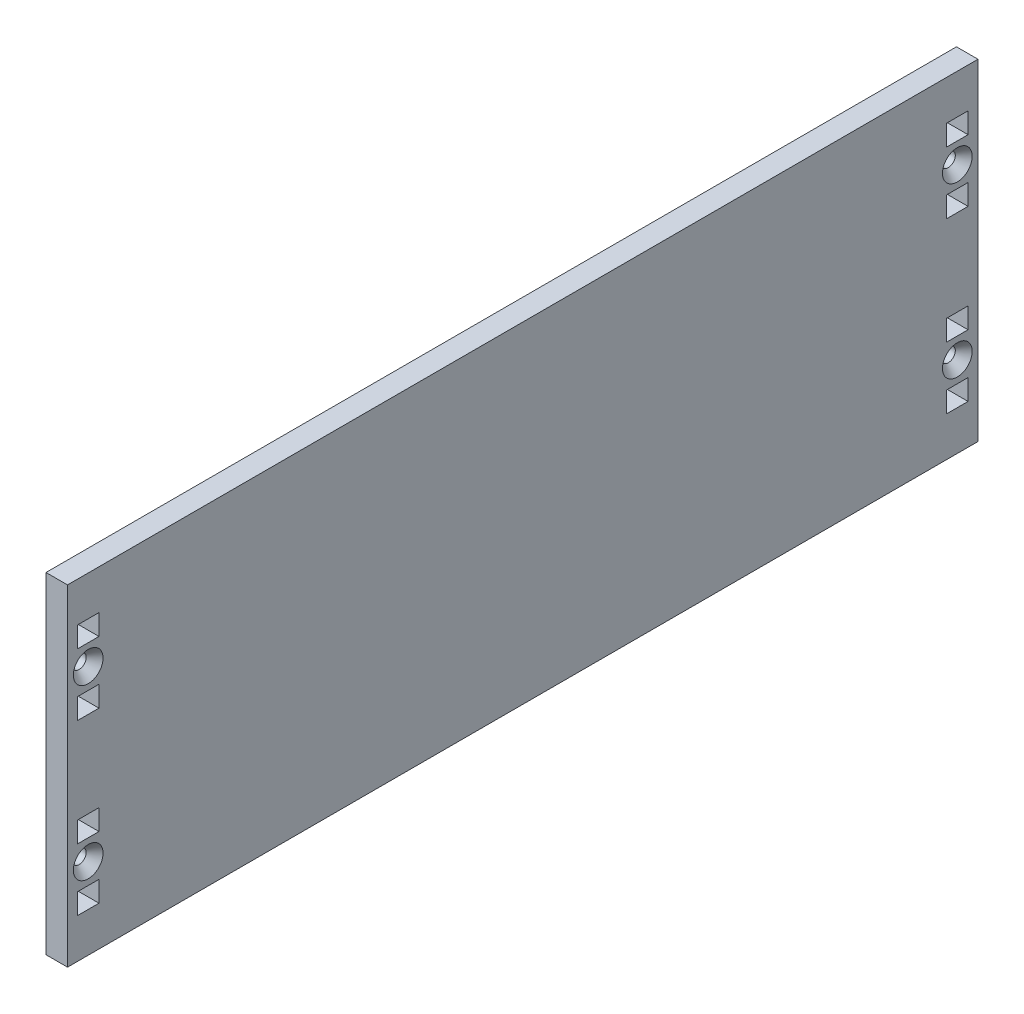
from build123d import *

# Parameters (mm, degrees)
SKETCH1_W                                         = 279.4
SKETCH1_H                                         = 101.6
SKETCH1_R                                         = 2.15265
SKETCH1_W_2                                       = 6.604
SKETCH1_H_2                                       = 6.35
BOSS_EXTRUDE1_DEPTH                               = 6.604
CSK_FOR_8_FLAT_HEAD_SOCKET_CAP_SCREW1_D           = 4.3053
CSK_FOR_8_FLAT_HEAD_SOCKET_CAP_SCREW1_CSINK_D     = 9.1186
CSK_FOR_8_FLAT_HEAD_SOCKET_CAP_SCREW1_CSINK_ANGLE = 82


with BuildPart() as part:
    # Sketch1 → Boss-Extrude1 (new body)
    with BuildSketch(Plane(origin=(0, 0, 0), x_dir=(0, 0, -1), z_dir=(1, 0, 0))):
        with Locations((0, -50.8)):
            Rectangle(SKETCH1_W, SKETCH1_H)
        with Locations((-133.35, -24.8793)):
            Circle(SKETCH1_R, mode=Mode.SUBTRACT)
        with Locations((-133.35, -76.7207)):
            Circle(SKETCH1_R, mode=Mode.SUBTRACT)
        with Locations((133.35, -24.8793)):
            Circle(SKETCH1_R, mode=Mode.SUBTRACT)
        with Locations((133.35, -76.720700102)):
            Circle(SKETCH1_R, mode=Mode.SUBTRACT)
        with Locations((-133.35, -34.4043)):
            Rectangle(SKETCH1_W_2, SKETCH1_H_2, mode=Mode.SUBTRACT)
        with Locations((-133.35, -15.3543)):
            Rectangle(SKETCH1_W_2, SKETCH1_H_2, mode=Mode.SUBTRACT)
        with Locations((-133.35, -86.2457)):
            Rectangle(SKETCH1_W_2, SKETCH1_H_2, mode=Mode.SUBTRACT)
        with Locations((-133.35, -67.1957)):
            Rectangle(SKETCH1_W_2, SKETCH1_H_2, mode=Mode.SUBTRACT)
        with Locations((133.35, -15.3543)):
            Rectangle(SKETCH1_W_2, SKETCH1_H_2, mode=Mode.SUBTRACT)
        with Locations((133.35, -34.4043)):
            Rectangle(SKETCH1_W_2, SKETCH1_H_2, mode=Mode.SUBTRACT)
        with Locations((133.35, -67.195700102)):
            Rectangle(SKETCH1_W_2, SKETCH1_H_2, mode=Mode.SUBTRACT)
        with Locations((133.35, -86.245700102)):
            Rectangle(SKETCH1_W_2, SKETCH1_H_2, mode=Mode.SUBTRACT)
    extrude(amount=BOSS_EXTRUDE1_DEPTH)

    # CSK for #8 Flat Head Socket Cap Screw1 (through all)
    with Locations(Plane(origin=(6.604, 0, 0), x_dir=(0, 0, -1), z_dir=(1, 0, 0))):
        with Locations((-133.35, -24.8793), (-133.35, -76.7207), (133.35, -24.8793), (133.35, -76.720700102)):
            CounterSinkHole(CSK_FOR_8_FLAT_HEAD_SOCKET_CAP_SCREW1_D / 2, CSK_FOR_8_FLAT_HEAD_SOCKET_CAP_SCREW1_CSINK_D / 2, counter_sink_angle=CSK_FOR_8_FLAT_HEAD_SOCKET_CAP_SCREW1_CSINK_ANGLE)


solid = part.part
